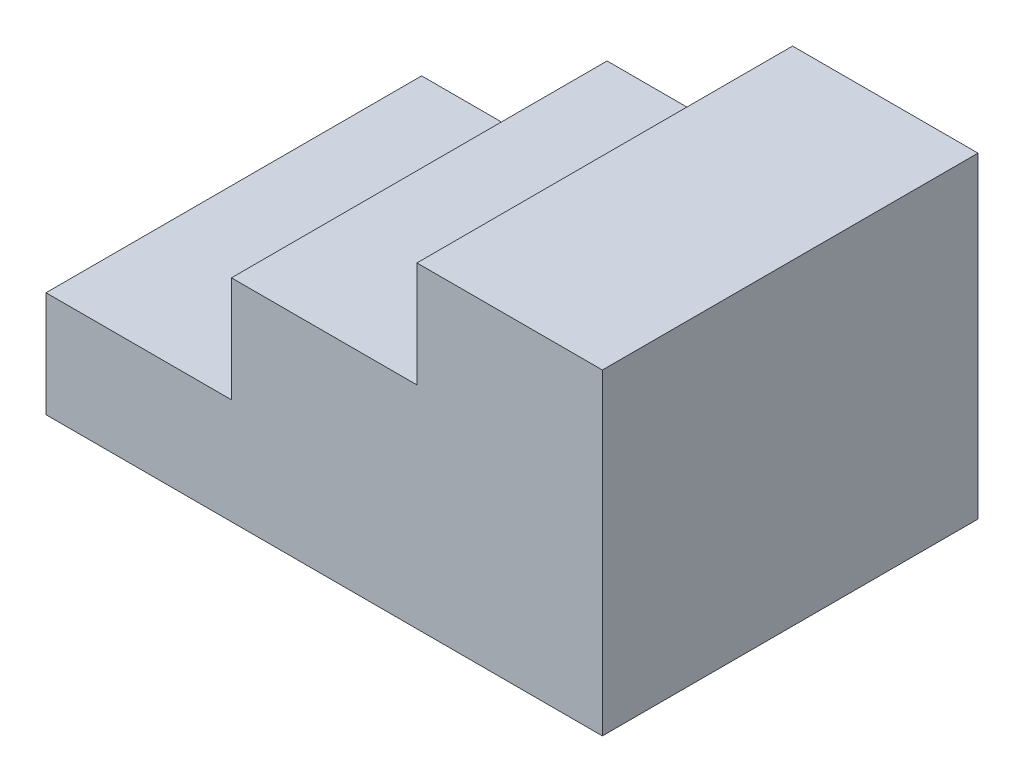
from build123d import *

# Parameters (mm, degrees)
BOSS_EXTRUDE1_DEPTH = 609.6


with BuildPart() as part:
    # Sketch1 → Boss-Extrude1 (new body)
    with BuildSketch(Plane.XY):
        Polygon((0, 0), (902.97, 0), (902.97, 514.35), (601.98, 514.35), (601.98, 342.9), (300.99, 342.9), (300.99, 171.45), (0, 171.45), align=None)
    extrude(amount=BOSS_EXTRUDE1_DEPTH)


solid = part.part
